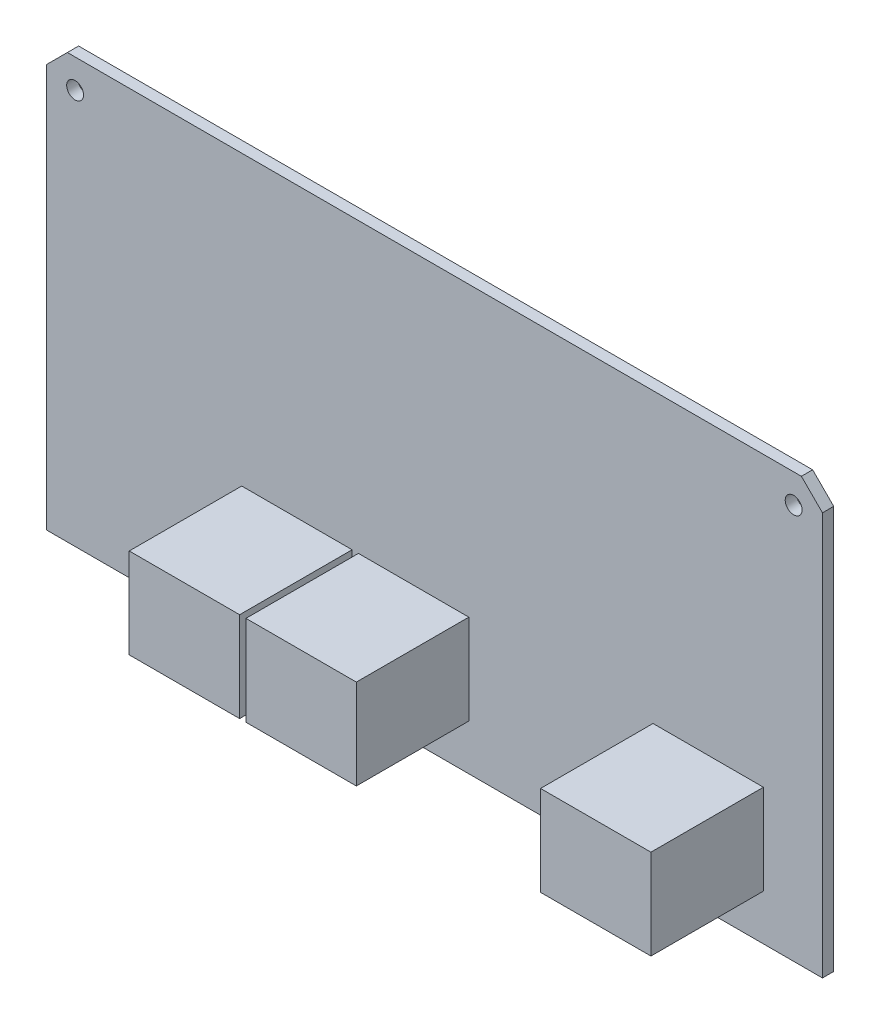
from build123d import *

# Parameters (mm, degrees)
CROQUIS1_R              = 1.2
SALIENTE_EXTRUIR1_DEPTH = 1.6
CROQUIS2_W              = 15.7
CROQUIS2_H              = 12.8
SALIENTE_EXTRUIR2_DEPTH = 16


with BuildPart() as part:
    # Croquis1 → Saliente-Extruir1 (new body)
    with BuildSketch(Plane.XY):
        Polygon((55.2, -30.15), (-55.2, -30.15), (-55.2, 27.15), (-52.2, 30.15), (52.2, 30.15), (55.2, 27.15), align=None)
        with Locations((-51.1, 26.05)):
            Circle(CROQUIS1_R, mode=Mode.SUBTRACT)
        with Locations((51.1, 26.05)):
            Circle(CROQUIS1_R, mode=Mode.SUBTRACT)
    extrude(amount=SALIENTE_EXTRUIR1_DEPTH)

    # Croquis2 → Saliente-Extruir2 (add)
    with BuildSketch(Plane.XY.offset(1.6)):
        with Locations((-19.55, -17.25)):
            Rectangle(CROQUIS2_W, CROQUIS2_H)
        with Locations((-2.95, -17.25)):
            Rectangle(CROQUIS2_W, CROQUIS2_H)
        with Locations((38.95, -17.25)):
            Rectangle(CROQUIS2_W, CROQUIS2_H)
    extrude(amount=SALIENTE_EXTRUIR2_DEPTH)


solid = part.part
